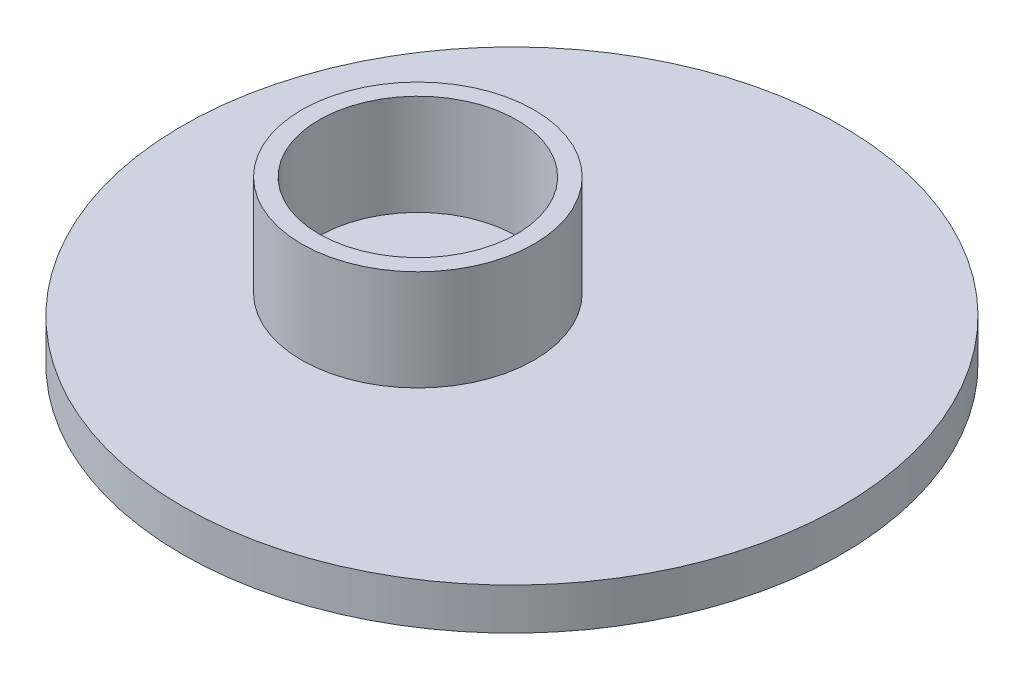
from build123d import *

# Parameters (mm, degrees)
SKETCH1_R           = 9.5
BOSS_EXTRUDE1_DEPTH = 1.2
SKETCH2_R           = 3.35
SKETCH2_R_2         = 2.85
BOSS_EXTRUDE2_DEPTH = 2.9


with BuildPart() as part:
    # Sketch1 → Boss-Extrude1 (new body)
    with BuildSketch(Plane(origin=(0, 0, 0), x_dir=(1, 0, 0), z_dir=(0, 1, 0))):
        Circle(SKETCH1_R)
    extrude(amount=BOSS_EXTRUDE1_DEPTH)

    # Sketch2 → Boss-Extrude2 (add)
    with BuildSketch(Plane(origin=(0, 1.2, 0), x_dir=(1, 0, 0), z_dir=(0, 1, 0))):
        with Locations((-1.927795475, -0.783841227)):
            Circle(SKETCH2_R)
        with Locations((-1.927795475, -0.783841227)):
            Circle(SKETCH2_R_2, mode=Mode.SUBTRACT)
    extrude(amount=BOSS_EXTRUDE2_DEPTH)


solid = part.part
